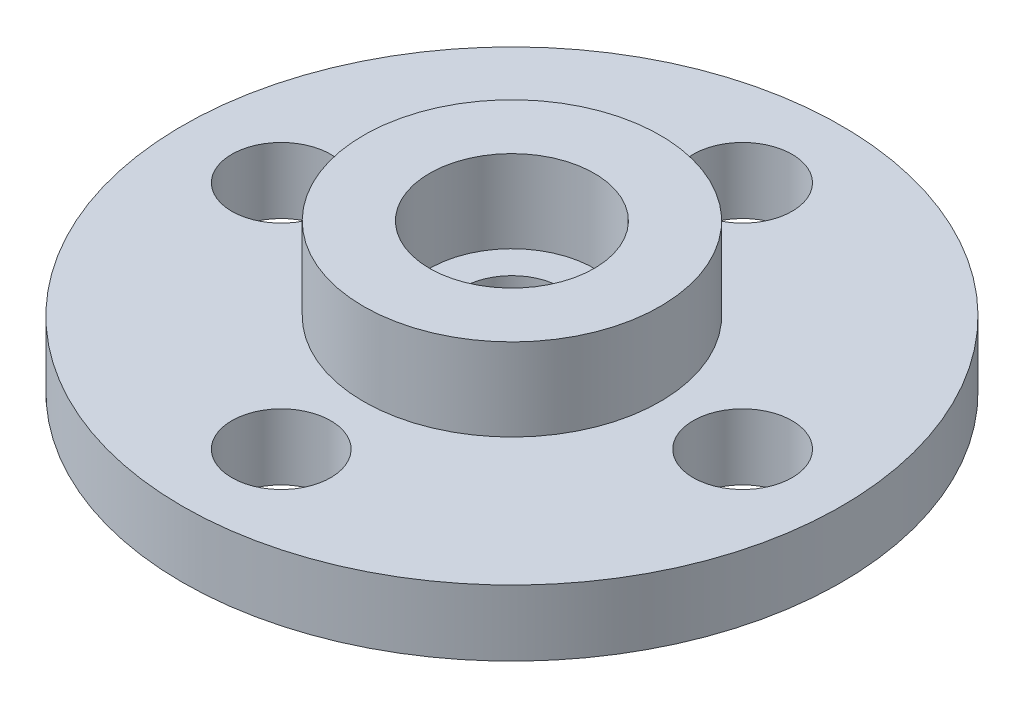
from build123d import *

# Parameters (mm, degrees)
SKETCH_1_R          = 10
EXTRUDE_1_DEPTH     = 2
SKETCH_2_R          = 1.5
CUT_EXTRUDE_1_DEPTH = 2
SKETCH_3_R          = 4.5
SKETCH_3_R_2        = 2.5
EXTRUDE_2_DEPTH     = 2.5


with BuildPart() as part:
    # 草图1 → 凸台-拉伸1 (new body)
    with BuildSketch(Plane(origin=(0, 0, 0), x_dir=(1, 0, 0), z_dir=(0, 1, 0))):
        Circle(SKETCH_1_R)
    extrude(amount=EXTRUDE_1_DEPTH)

    # 草图2 → 切除-拉伸1 (cut)
    with BuildSketch(Plane(origin=(0, 2, 0), x_dir=(1, 0, 0), z_dir=(0, 1, 0))):
        Circle(SKETCH_2_R)
        with Locations((0, 7)):
            Circle(SKETCH_2_R)
        with Locations((7, 0)):
            Circle(SKETCH_2_R)
        with Locations((0, -7)):
            Circle(SKETCH_2_R)
        with Locations((-7, 0)):
            Circle(SKETCH_2_R)
    extrude(amount=-CUT_EXTRUDE_1_DEPTH, mode=Mode.SUBTRACT)

    # 草图3 → 凸台-拉伸2 (add)
    with BuildSketch(Plane(origin=(0, 2, 0), x_dir=(1, 0, 0), z_dir=(0, 1, 0))):
        Circle(SKETCH_3_R)
        Circle(SKETCH_3_R_2, mode=Mode.SUBTRACT)
    extrude(amount=EXTRUDE_2_DEPTH)


solid = part.part
